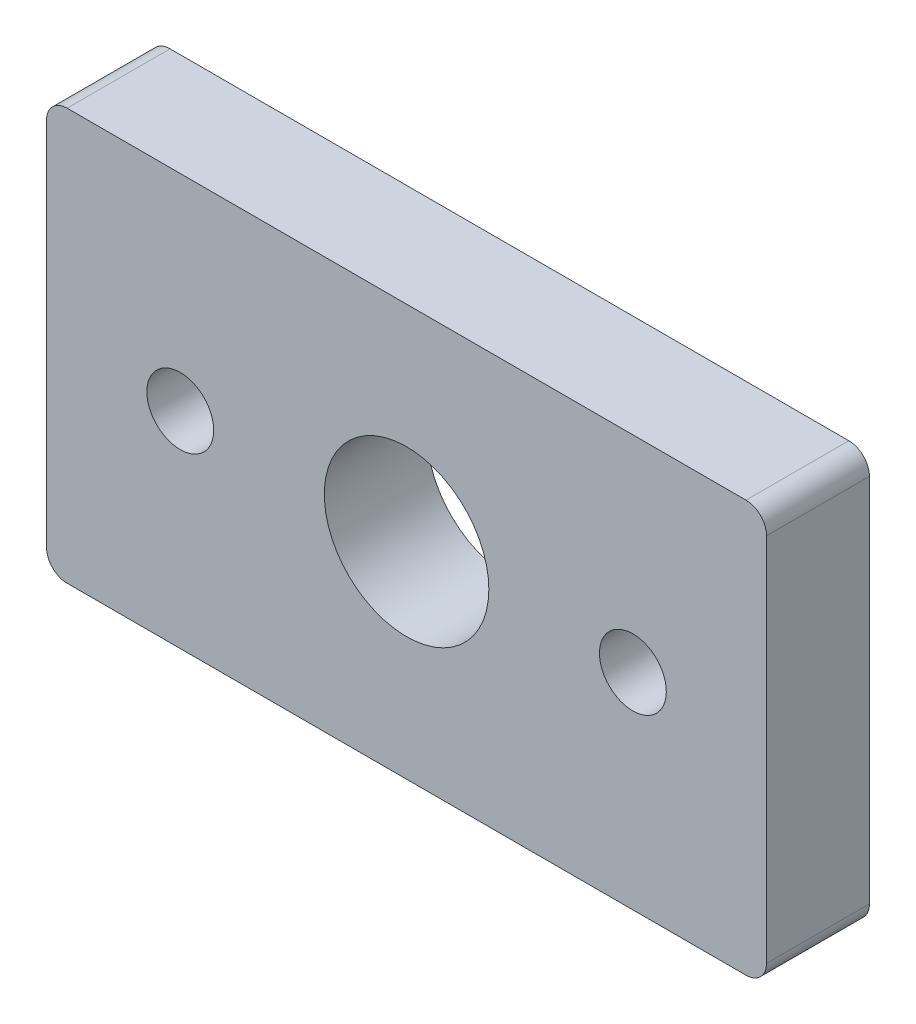
from build123d import *

# Parameters (mm, degrees)
SKETCH1_W           = 35
SKETCH1_H           = 20
SKETCH1_R           = 4
SKETCH1_R_2         = 1.625
BOSS_EXTRUDE1_DEPTH = 5
FILLET1_R           = 1


with BuildPart() as part:
    # Sketch1 → Boss-Extrude1 (new body)
    with BuildSketch(Plane.XY):
        with Locations((17.5, 10)):
            Rectangle(SKETCH1_W, SKETCH1_H)
        with Locations((17.5, 10)):
            Circle(SKETCH1_R, mode=Mode.SUBTRACT)
        with Locations((28.5, 10)):
            Circle(SKETCH1_R_2, mode=Mode.SUBTRACT)
        with Locations((6.5, 10)):
            Circle(SKETCH1_R_2, mode=Mode.SUBTRACT)
    extrude(amount=BOSS_EXTRUDE1_DEPTH)

    # Fillet1
    fillet1_edges = [part.edges().sort_by_distance(p)[0] for p in [
        (0, 20, 2.5),
        (35, 20, 2.5),
        (35, 0, 2.5),
        (0, 0, 2.5),
    ]]
    fillet(fillet1_edges, radius=FILLET1_R)


solid = part.part
